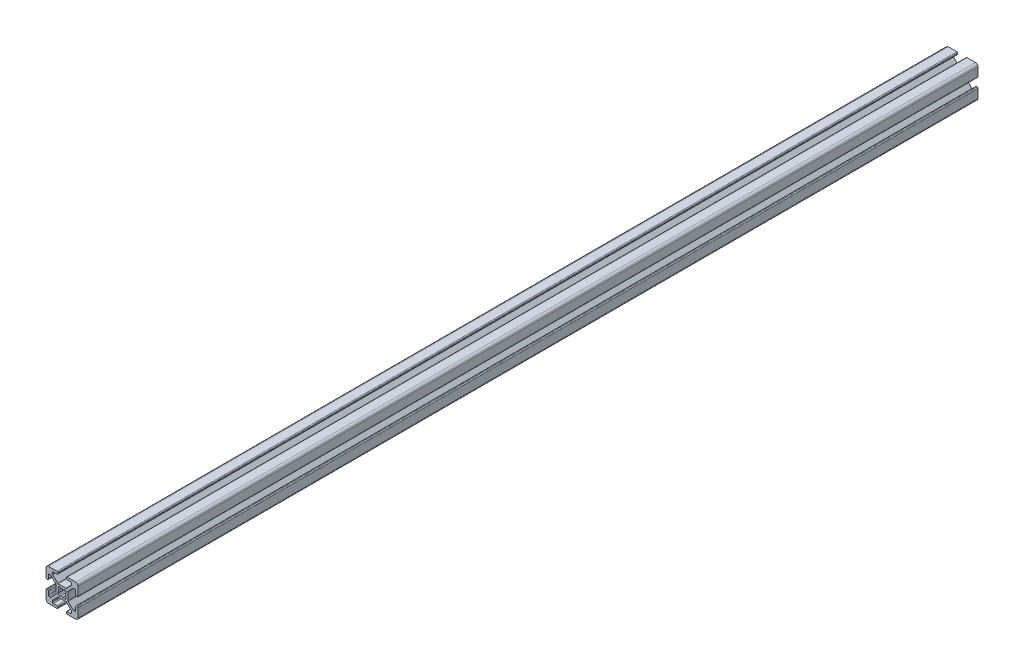
from build123d import *

# Parameters (mm, degrees)
METRIC_AL_EXTRUSION_20_2020_PROFILE_1_DEPTH = 560


with BuildPart() as part:
    # Sketch19 → Metric al extrusion 20-2020 PROFILE(1) (new body)
    with BuildSketch(Plane(origin=(0, 0, 0), x_dir=(-1, 0, 0), z_dir=(0, 0, -1))):
        with BuildLine():
            Line((9.895192042, 3.57078143), (9.411192042, 3.57078143))
            ThreePointArc((9.411192042, 3.57078143), (9.051981797, 3.719571185), (8.903192042, 4.07878143))
            Line((8.903192042, 4.07878143), (8.903192042, 6.42778143))
            ThreePointArc((8.903192042, 6.42778143), (8.754402286, 6.786991675), (8.395192042, 6.93578143))
            Line((8.395192042, 6.93578143), (7.669272703, 6.93578143))
            ThreePointArc((7.669272703, 6.93578143), (7.474869519, 6.897112233), (7.310062458, 6.786991675))
            Line((7.310062458, 6.786991675), (4.206981797, 3.683911014))
            ThreePointArc((4.206981797, 3.683911014), (4.096861239, 3.519103952), (4.058192042, 3.324700769))
            Line((4.058192042, 3.324700769), (4.058192042, -1.443137908))
            ThreePointArc((4.058192042, -1.443137908), (4.096861239, -1.637541092), (4.206981797, -1.802348153))
            Line((4.206981797, -1.802348153), (7.310062458, -4.905428815))
            ThreePointArc((7.310062458, -4.905428815), (7.474869519, -5.015549372), (7.669272703, -5.05421857))
            Line((7.669272703, -5.05421857), (8.395192042, -5.05421857))
            ThreePointArc((8.395192042, -5.05421857), (8.754402286, -4.905428815), (8.903192042, -4.54621857))
            Line((8.903192042, -4.54621857), (8.903192042, -2.19721857))
            ThreePointArc((8.903192042, -2.19721857), (9.051981797, -1.838008325), (9.411192042, -1.68921857))
            Line((9.411192042, -1.68921857), (9.895192042, -1.68921857))
            ThreePointArc((9.895192042, -1.68921857), (10.254402286, -1.838008325), (10.403192042, -2.19721857))
            Line((10.403192042, -2.19721857), (10.403192042, -7.55921857))
            ThreePointArc((10.403192042, -7.55921857), (9.963852213, -8.619878742), (8.903192042, -9.05921857))
            Line((8.903192042, -9.05921857), (3.541192042, -9.05921857))
            ThreePointArc((3.541192042, -9.05921857), (3.181981797, -8.910428815), (3.033192042, -8.55121857))
            Line((3.033192042, -8.55121857), (3.033192042, -8.06721857))
            ThreePointArc((3.033192042, -8.06721857), (3.181981797, -7.708008325), (3.541192042, -7.55921857))
            Line((3.541192042, -7.55921857), (5.890192042, -7.55921857))
            ThreePointArc((5.890192042, -7.55921857), (6.249402286, -7.410428815), (6.398192042, -7.05121857))
            Line((6.398192042, -7.05121857), (6.398192042, -6.325299231))
            ThreePointArc((6.398192042, -6.325299231), (6.359522844, -6.130896048), (6.249402286, -5.966088986))
            Line((6.249402286, -5.966088986), (3.146321625, -2.863008325))
            ThreePointArc((3.146321625, -2.863008325), (2.981514564, -2.752887767), (2.78711138, -2.71421857))
            Line((2.78711138, -2.71421857), (-1.980727297, -2.71421857))
            ThreePointArc((-1.980727297, -2.71421857), (-2.175130481, -2.752887767), (-2.339937542, -2.863008325))
            Line((-2.339937542, -2.863008325), (-5.443018203, -5.966088986))
            ThreePointArc((-5.443018203, -5.966088986), (-5.553138761, -6.130896048), (-5.591807958, -6.325299231))
            Line((-5.591807958, -6.325299231), (-5.591807958, -7.05121857))
            ThreePointArc((-5.591807958, -7.05121857), (-5.443018203, -7.410428815), (-5.083807958, -7.55921857))
            Line((-5.083807958, -7.55921857), (-2.734807958, -7.55921857))
            ThreePointArc((-2.734807958, -7.55921857), (-2.375597714, -7.708008325), (-2.226807958, -8.06721857))
            Line((-2.226807958, -8.06721857), (-2.226807958, -8.55121857))
            ThreePointArc((-2.226807958, -8.55121857), (-2.375597714, -8.910428815), (-2.734807958, -9.05921857))
            Line((-2.734807958, -9.05921857), (-8.096807958, -9.05921857))
            ThreePointArc((-8.096807958, -9.05921857), (-9.15746813, -8.619878742), (-9.596807958, -7.55921857))
            Line((-9.596807958, -7.55921857), (-9.596807958, -2.19721857))
            ThreePointArc((-9.596807958, -2.19721857), (-9.448018203, -1.838008325), (-9.088807958, -1.68921857))
            Line((-9.088807958, -1.68921857), (-8.604807958, -1.68921857))
            ThreePointArc((-8.604807958, -1.68921857), (-8.245597714, -1.838008325), (-8.096807958, -2.19721857))
            Line((-8.096807958, -2.19721857), (-8.096807958, -4.54621857))
            ThreePointArc((-8.096807958, -4.54621857), (-7.948018203, -4.905428815), (-7.588807958, -5.05421857))
            Line((-7.588807958, -5.05421857), (-6.86288862, -5.05421857))
            ThreePointArc((-6.86288862, -5.05421857), (-6.668485436, -5.015549372), (-6.503678375, -4.905428815))
            Line((-6.503678375, -4.905428815), (-3.400597714, -1.802348153))
            ThreePointArc((-3.400597714, -1.802348153), (-3.290477156, -1.637541092), (-3.251807958, -1.443137908))
            Line((-3.251807958, -1.443137908), (-3.251807958, 3.324700769))
            ThreePointArc((-3.251807958, 3.324700769), (-3.290477156, 3.519103952), (-3.400597714, 3.683911014))
            Line((-3.400597714, 3.683911014), (-6.503678375, 6.786991675))
            ThreePointArc((-6.503678375, 6.786991675), (-6.668485436, 6.897112233), (-6.86288862, 6.93578143))
            Line((-6.86288862, 6.93578143), (-7.588807958, 6.93578143))
            ThreePointArc((-7.588807958, 6.93578143), (-7.948018203, 6.786991675), (-8.096807958, 6.42778143))
            Line((-8.096807958, 6.42778143), (-8.096807958, 4.07878143))
            ThreePointArc((-8.096807958, 4.07878143), (-8.245597714, 3.719571185), (-8.604807958, 3.57078143))
            Line((-8.604807958, 3.57078143), (-9.088807958, 3.57078143))
            ThreePointArc((-9.088807958, 3.57078143), (-9.448018203, 3.719571185), (-9.596807958, 4.07878143))
            Line((-9.596807958, 4.07878143), (-9.596807958, 9.44078143))
            ThreePointArc((-9.596807958, 9.44078143), (-9.15746813, 10.501441602), (-8.096807958, 10.94078143))
            Line((-8.096807958, 10.94078143), (-2.734807958, 10.94078143))
            ThreePointArc((-2.734807958, 10.94078143), (-2.375597714, 10.791991675), (-2.226807958, 10.43278143))
            Line((-2.226807958, 10.43278143), (-2.226807958, 9.94878143))
            ThreePointArc((-2.226807958, 9.94878143), (-2.375597714, 9.589571185), (-2.734807958, 9.44078143))
            Line((-2.734807958, 9.44078143), (-5.083807958, 9.44078143))
            ThreePointArc((-5.083807958, 9.44078143), (-5.443018203, 9.291991675), (-5.591807958, 8.93278143))
            Line((-5.591807958, 8.93278143), (-5.591807958, 8.206862092))
            ThreePointArc((-5.591807958, 8.206862092), (-5.553138761, 8.012458908), (-5.443018203, 7.847651847))
            Line((-5.443018203, 7.847651847), (-2.339937542, 4.744571185))
            ThreePointArc((-2.339937542, 4.744571185), (-2.175130481, 4.634450628), (-1.980727297, 4.59578143))
            Line((-1.980727297, 4.59578143), (2.78711138, 4.59578143))
            ThreePointArc((2.78711138, 4.59578143), (2.981514564, 4.634450628), (3.146321625, 4.744571185))
            Line((3.146321625, 4.744571185), (6.249402286, 7.847651847))
            ThreePointArc((6.249402286, 7.847651847), (6.359522844, 8.012458908), (6.398192042, 8.206862092))
            Line((6.398192042, 8.206862092), (6.398192042, 8.93278143))
            ThreePointArc((6.398192042, 8.93278143), (6.249402286, 9.291991675), (5.890192042, 9.44078143))
            Line((5.890192042, 9.44078143), (3.541192042, 9.44078143))
            ThreePointArc((3.541192042, 9.44078143), (3.181981797, 9.589571185), (3.033192042, 9.94878143))
            Line((3.033192042, 9.94878143), (3.033192042, 10.43278143))
            ThreePointArc((3.033192042, 10.43278143), (3.181981797, 10.791991675), (3.541192042, 10.94078143))
            Line((3.541192042, 10.94078143), (8.903192042, 10.94078143))
            ThreePointArc((8.903192042, 10.94078143), (9.963852213, 10.501441602), (10.403192042, 9.44078143))
            Line((10.403192042, 9.44078143), (10.403192042, 4.07878143))
            ThreePointArc((10.403192042, 4.07878143), (10.254402286, 3.719571185), (9.895192042, 3.57078143))
        make_face()
        with BuildLine():
            Line((2.528092885, -1.363724536), (2.707698008, -1.184119414))
            ThreePointArc((2.707698008, -1.184119414), (2.909130058, -0.415686381), (2.338325548, 0.136804712))
            ThreePointArc((2.338325548, 0.136804712), (2.498692042, 0.94078143), (2.338325548, 1.744758148))
            ThreePointArc((2.338325548, 1.744758148), (2.909130058, 2.297249241), (2.707698008, 3.065682274))
            Line((2.707698008, 3.065682274), (2.528092885, 3.245287396))
            ThreePointArc((2.528092885, 3.245287396), (1.759659852, 3.446719447), (1.20716876, 2.875914936))
            ThreePointArc((1.20716876, 2.875914936), (0.403192042, 3.03628143), (-0.400784676, 2.875914936))
            ThreePointArc((-0.400784676, 2.875914936), (-0.953275769, 3.446719447), (-1.721708802, 3.245287396))
            Line((-1.721708802, 3.245287396), (-1.901313925, 3.065682274))
            ThreePointArc((-1.901313925, 3.065682274), (-2.102745975, 2.297249241), (-1.531941465, 1.744758148))
            ThreePointArc((-1.531941465, 1.744758148), (-1.692307958, 0.94078143), (-1.531941465, 0.136804712))
            ThreePointArc((-1.531941465, 0.136804712), (-2.102745975, -0.415686381), (-1.901313925, -1.184119414))
            Line((-1.901313925, -1.184119414), (-1.721708802, -1.363724536))
            ThreePointArc((-1.721708802, -1.363724536), (-0.953275769, -1.565156587), (-0.400784676, -0.994352076))
            ThreePointArc((-0.400784676, -0.994352076), (0.403192042, -1.15471857), (1.20716876, -0.994352076))
            ThreePointArc((1.20716876, -0.994352076), (1.759659852, -1.565156587), (2.528092885, -1.363724536))
        make_face(mode=Mode.SUBTRACT)
    extrude(amount=METRIC_AL_EXTRUSION_20_2020_PROFILE_1_DEPTH)


solid = part.part
